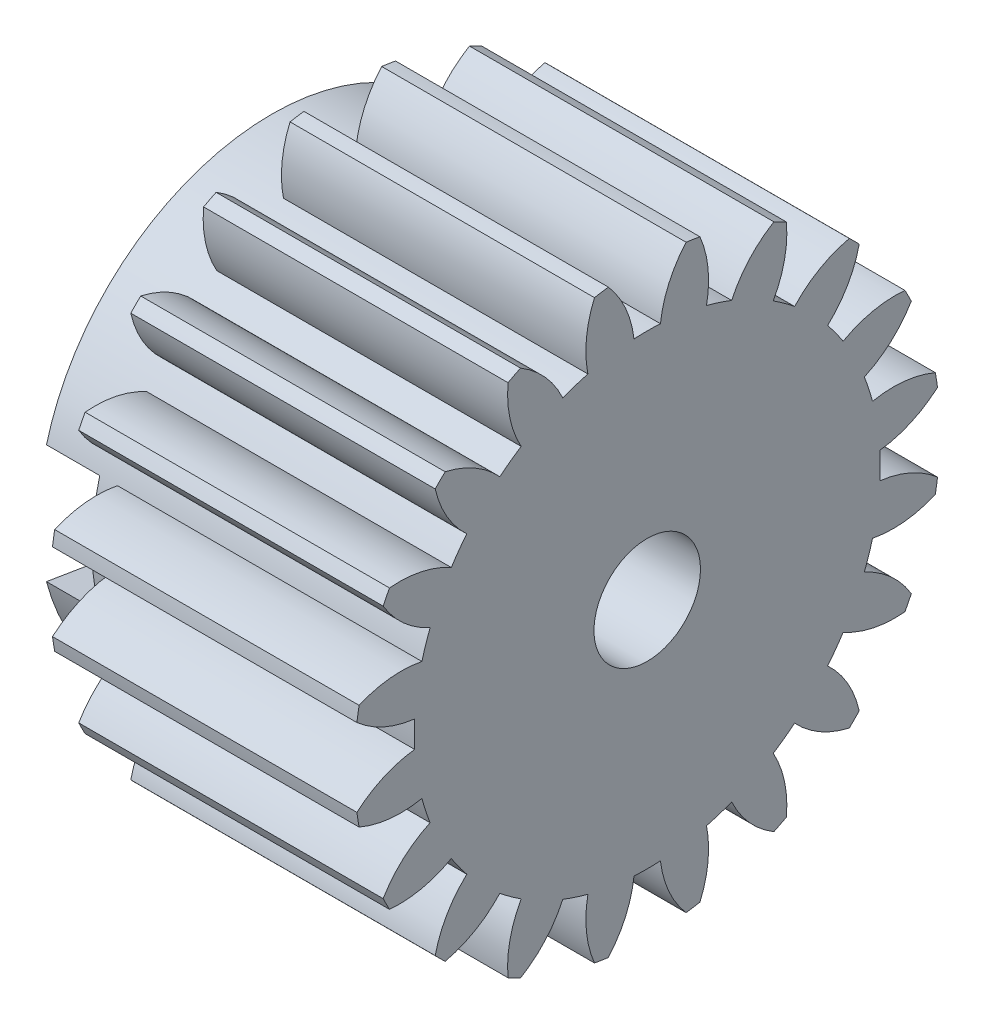
from build123d import *
from build123d.topology import SkipClean

# Parameters (mm, degrees)
BASPROSKE_W         = 10
BASPROSKE_H         = 16.5
TOOTHCUT_DEPTH      = 26.38700455
TEETHCUTS_COUNT     = 20
TEETHCUTS_ANGLE     = 342
HUBNEAONESKE_R      = 13.124
HUBNEARONE_DEPTH    = 6.0000508
BORSKE_R            = 0.4
BORE_DEPTH          = 16.0000508
CUT_EXTRUDE1_DEPTH  = 5
BOSS_EXTRUDE1_DEPTH = 7.15
SKETCH4_R           = 13.124
CUT_EXTRUDE2_DEPTH  = 2
SKETCH6_R           = 3
CUT_EXTRUDE3_DEPTH  = 13
SKETCH7_R           = 1.8
CUT_EXTRUDE4_DEPTH  = 27.531296609


with BuildPart() as part:
    # BasProSke → Base-Revolve (revolve)
    with BuildSketch(Plane(origin=(0, 0, 0), x_dir=(1, 0, 0), z_dir=(0, 1, 0)), mode=Mode.PRIVATE) as base_revolve_sk:
        with Locations((5, 8.25)):
            Rectangle(BASPROSKE_W, BASPROSKE_H)
    revolve(base_revolve_sk.sketch.rotate(Axis((-10, 0, 0), (1, 0, 0)), 180), axis=Axis((-10, 0, 0), (1, 0, 0)))

    # TooCutSke → ToothCut (cut, through all)
    with BuildSketch(Plane(origin=(0, 0, 0), x_dir=(0, 0, -1), z_dir=(1, 0, 0))):
        with BuildLine():
            ThreePointArc((0.74381438, 13.102904875), (0, 13.124), (-0.74381438, 13.102904875))
            ThreePointArc((-0.74381438, 13.102904875), (-1.226473103, 14.852072512), (-2.209965745, 16.376962373))
            ThreePointArc((-2.209965745, 16.376962373), (0, 16.5254), (2.209965745, 16.376962373))
            ThreePointArc((2.209965745, 16.376962373), (1.226473103, 14.852072512), (0.74381438, 13.102904875))
        make_face()
    toothcut = extrude(amount=TOOTHCUT_DEPTH, mode=Mode.SUBTRACT)

    # TeethCuts: ToothCut ×20 about axis
    teethcuts_axis = Axis((-10, 0, 0), (1, 0, 0))
    for i in range(1, TEETHCUTS_COUNT):
        add(toothcut.rotate(teethcuts_axis, i * TEETHCUTS_ANGLE / (TEETHCUTS_COUNT - 1)), mode=Mode.SUBTRACT)

    # HubNeaOneSke → HubNearOne (add)
    with SkipClean():  # the faces are left unmerged after this step: merging them gives an invalid solid
        with BuildSketch(Plane.ZY):
            Circle(HUBNEAONESKE_R)
        extrude(amount=HUBNEARONE_DEPTH)

    # BorSke → Bore (cut, symmetric)
    with SkipClean():  # the faces are left unmerged after this step: merging them gives an invalid solid
        with BuildSketch(Plane(origin=(0, 0, 0), x_dir=(0, 0, -1), z_dir=(1, 0, 0))):
            with Locations(Location((0, 0, 0), (0, 0, 180))):
                Circle(BORSKE_R)
        extrude(amount=BORE_DEPTH, both=True, mode=Mode.SUBTRACT)

    # Sketch1 → Cut-Extrude1 (cut)
    with SkipClean():  # the faces are left unmerged after this step: merging them gives an invalid solid
        with BuildSketch(Plane.ZY.offset(6.0000508)):
            with BuildLine():
                Line((15.95, 2.8), (4.417295553, 4.7))
                ThreePointArc((4.417295553, 4.7), (0, 6.45), (-4.417295553, 4.7))
                Line((-4.417295553, 4.7), (-15.95, 2.8))
                ThreePointArc((-15.95, 2.8), (-18.75, 0), (-15.95, -2.8))
                Line((-15.95, -2.8), (-4.417295553, -4.7))
                ThreePointArc((-4.417295553, -4.7), (0, -6.45), (4.417295553, -4.7))
                Line((4.417295553, -4.7), (15.95, -2.8))
                ThreePointArc((15.95, -2.8), (18.75, 0), (15.95, 2.8))
            make_face()
        extrude(amount=-CUT_EXTRUDE1_DEPTH, mode=Mode.SUBTRACT)

    # Sketch2 → Boss-Extrude1 (add)
    with SkipClean():  # the faces are left unmerged after this step: merging them gives an invalid solid
        with BuildSketch(Plane(origin=(10, 0, 0), x_dir=(0, 0, -1), z_dir=(1, 0, 0))):
            with BuildLine():
                ThreePointArc((-16.354046896, 2.189783121), (-14.838129876, 1.220250755), (-13.102904875, 0.74381438))
                ThreePointArc((-13.102904875, 0.74381438), (-13.124, 0), (-13.102904875, -0.74381438))
                ThreePointArc((-13.102904875, -0.74381438), (-14.838129876, -1.220250755), (-16.354046896, -2.189783121))
                ThreePointArc((-16.354046896, -2.189783121), (-16.29685762, -2.581168673), (-16.230303067, -2.971070911))
                ThreePointArc((-16.230303067, -2.971070911), (-14.488978329, -3.424706864), (-12.691454348, -3.341610769))
                ThreePointArc((-12.691454348, -3.341610769), (-12.48166572, -4.055539034), (-12.23175178, -4.756429795))
                ThreePointArc((-12.23175178, -4.756429795), (-13.734821887, -5.745761728), (-14.87694267, -7.136285925))
                ThreePointArc((-14.87694267, -7.136285925), (-14.701607649, -7.490843246), (-14.51782409, -7.841095822))
                ThreePointArc((-14.51782409, -7.841095822), (-12.721544632, -7.734430314), (-11.037675843, -7.099935773))
                ThreePointArc((-11.037675843, -7.099935773), (-10.617539034, -7.714093651), (-10.163269596, -8.303452722))
                ThreePointArc((-10.163269596, -8.303452722), (-11.287053836, -9.708837511), (-11.943579641, -11.38423934))
                ThreePointArc((-11.943579641, -11.38423934), (-11.66726189, -11.66726189), (-11.38423934, -11.943579641))
                ThreePointArc((-11.38423934, -11.943579641), (-9.708837511, -11.287053836), (-8.303452722, -10.163269596))
                ThreePointArc((-8.303452722, -10.163269596), (-7.714093651, -10.617539034), (-7.099935773, -11.037675843))
                ThreePointArc((-7.099935773, -11.037675843), (-7.734430314, -12.721544632), (-7.841095822, -14.51782409))
                ThreePointArc((-7.841095822, -14.51782409), (-7.490843246, -14.701607649), (-7.136285925, -14.87694267))
                ThreePointArc((-7.136285925, -14.87694267), (-5.745761728, -13.734821887), (-4.756429795, -12.23175178))
                ThreePointArc((-4.756429795, -12.23175178), (-4.055539034, -12.48166572), (-3.341610769, -12.691454348))
                ThreePointArc((-3.341610769, -12.691454348), (-3.424706864, -14.488978329), (-2.971070911, -16.230303067))
                ThreePointArc((-2.971070911, -16.230303067), (-2.581168673, -16.29685762), (-2.189783121, -16.354046896))
                ThreePointArc((-2.189783121, -16.354046896), (-1.220250755, -14.838129876), (-0.74381438, -13.102904875))
                ThreePointArc((-0.74381438, -13.102904875), (0, -13.124), (0.74381438, -13.102904875))
                ThreePointArc((0.74381438, -13.102904875), (1.220250755, -14.838129876), (2.189783121, -16.354046896))
                ThreePointArc((2.189783121, -16.354046896), (2.581168673, -16.29685762), (2.971070911, -16.230303067))
                ThreePointArc((2.971070911, -16.230303067), (3.424706864, -14.488978329), (3.341610769, -12.691454348))
                ThreePointArc((3.341610769, -12.691454348), (4.055539034, -12.48166572), (4.756429795, -12.23175178))
                ThreePointArc((4.756429795, -12.23175178), (5.745761728, -13.734821887), (7.136285925, -14.87694267))
                ThreePointArc((7.136285925, -14.87694267), (7.490843246, -14.701607649), (7.841095822, -14.51782409))
                ThreePointArc((7.841095822, -14.51782409), (7.734430314, -12.721544632), (7.099935773, -11.037675843))
                ThreePointArc((7.099935773, -11.037675843), (7.714093651, -10.617539034), (8.303452722, -10.163269596))
                ThreePointArc((8.303452722, -10.163269596), (9.708837511, -11.287053836), (11.38423934, -11.943579641))
                ThreePointArc((11.38423934, -11.943579641), (11.66726189, -11.66726189), (11.943579641, -11.38423934))
                ThreePointArc((11.943579641, -11.38423934), (11.287053836, -9.708837511), (10.163269596, -8.303452722))
                ThreePointArc((10.163269596, -8.303452722), (10.617539034, -7.714093651), (11.037675843, -7.099935773))
                ThreePointArc((11.037675843, -7.099935773), (12.721544632, -7.734430314), (14.51782409, -7.841095822))
                ThreePointArc((14.51782409, -7.841095822), (14.701607649, -7.490843246), (14.87694267, -7.136285925))
                ThreePointArc((14.87694267, -7.136285925), (13.734821887, -5.745761728), (12.23175178, -4.756429795))
                ThreePointArc((12.23175178, -4.756429795), (12.48166572, -4.055539034), (12.691454348, -3.341610769))
                ThreePointArc((12.691454348, -3.341610769), (14.488978329, -3.424706864), (16.230303067, -2.971070911))
                ThreePointArc((16.230303067, -2.971070911), (16.29685762, -2.581168673), (16.354046896, -2.189783121))
                ThreePointArc((16.354046896, -2.189783121), (14.838129876, -1.220250755), (13.102904875, -0.74381438))
                ThreePointArc((13.102904875, -0.74381438), (13.124, 0), (13.102904875, 0.74381438))
                ThreePointArc((13.102904875, 0.74381438), (14.838129876, 1.220250755), (16.354046896, 2.189783121))
                ThreePointArc((16.354046896, 2.189783121), (16.29685762, 2.581168673), (16.230303067, 2.971070911))
                ThreePointArc((16.230303067, 2.971070911), (14.488978329, 3.424706864), (12.691454348, 3.341610769))
                ThreePointArc((12.691454348, 3.341610769), (12.48166572, 4.055539034), (12.23175178, 4.756429795))
                ThreePointArc((12.23175178, 4.756429795), (13.734821887, 5.745761728), (14.87694267, 7.136285925))
                ThreePointArc((14.87694267, 7.136285925), (14.701607649, 7.490843246), (14.51782409, 7.841095822))
                ThreePointArc((14.51782409, 7.841095822), (12.721544632, 7.734430314), (11.037675843, 7.099935773))
                ThreePointArc((11.037675843, 7.099935773), (10.617539034, 7.714093651), (10.163269596, 8.303452722))
                ThreePointArc((10.163269596, 8.303452722), (11.287053836, 9.708837511), (11.943579641, 11.38423934))
                ThreePointArc((11.943579641, 11.38423934), (11.66726189, 11.66726189), (11.38423934, 11.943579641))
                ThreePointArc((11.38423934, 11.943579641), (9.708837511, 11.287053836), (8.303452722, 10.163269596))
                ThreePointArc((8.303452722, 10.163269596), (7.714093651, 10.617539034), (7.099935773, 11.037675843))
                ThreePointArc((7.099935773, 11.037675843), (7.734430314, 12.721544632), (7.841095822, 14.51782409))
                ThreePointArc((7.841095822, 14.51782409), (7.490843246, 14.701607649), (7.136285925, 14.87694267))
                ThreePointArc((7.136285925, 14.87694267), (5.745761728, 13.734821887), (4.756429795, 12.23175178))
                ThreePointArc((4.756429795, 12.23175178), (4.055539034, 12.48166572), (3.341610769, 12.691454348))
                ThreePointArc((3.341610769, 12.691454348), (3.424706864, 14.488978329), (2.971070911, 16.230303067))
                ThreePointArc((2.971070911, 16.230303067), (2.581168673, 16.29685762), (2.189783121, 16.354046896))
                ThreePointArc((2.189783121, 16.354046896), (1.220250755, 14.838129876), (0.74381438, 13.102904875))
                ThreePointArc((0.74381438, 13.102904875), (0, 13.124), (-0.74381438, 13.102904875))
                ThreePointArc((-0.74381438, 13.102904875), (-1.220250755, 14.838129876), (-2.189783121, 16.354046896))
                ThreePointArc((-2.189783121, 16.354046896), (-2.581168673, 16.29685762), (-2.971070911, 16.230303067))
                ThreePointArc((-2.971070911, 16.230303067), (-3.424706864, 14.488978329), (-3.341610769, 12.691454348))
                ThreePointArc((-3.341610769, 12.691454348), (-4.055539034, 12.48166572), (-4.756429795, 12.23175178))
                ThreePointArc((-4.756429795, 12.23175178), (-5.745761728, 13.734821887), (-7.136285925, 14.87694267))
                ThreePointArc((-7.136285925, 14.87694267), (-7.490843246, 14.701607649), (-7.841095822, 14.51782409))
                ThreePointArc((-7.841095822, 14.51782409), (-7.734430314, 12.721544632), (-7.099935773, 11.037675843))
                ThreePointArc((-7.099935773, 11.037675843), (-7.714093651, 10.617539034), (-8.303452722, 10.163269596))
                ThreePointArc((-8.303452722, 10.163269596), (-9.708837511, 11.287053836), (-11.38423934, 11.943579641))
                ThreePointArc((-11.38423934, 11.943579641), (-11.66726189, 11.66726189), (-11.943579641, 11.38423934))
                ThreePointArc((-11.943579641, 11.38423934), (-11.287053836, 9.708837511), (-10.163269596, 8.303452722))
                ThreePointArc((-10.163269596, 8.303452722), (-10.617539034, 7.714093651), (-11.037675843, 7.099935773))
                ThreePointArc((-11.037675843, 7.099935773), (-12.721544632, 7.734430314), (-14.51782409, 7.841095822))
                ThreePointArc((-14.51782409, 7.841095822), (-14.701607649, 7.490843246), (-14.87694267, 7.136285925))
                ThreePointArc((-14.87694267, 7.136285925), (-13.734821887, 5.745761728), (-12.23175178, 4.756429795))
                ThreePointArc((-12.23175178, 4.756429795), (-12.48166572, 4.055539034), (-12.691454348, 3.341610769))
                ThreePointArc((-12.691454348, 3.341610769), (-14.488978329, 3.424706864), (-16.230303067, 2.971070911))
                ThreePointArc((-16.230303067, 2.971070911), (-16.29685762, 2.581168673), (-16.354046896, 2.189783121))
            make_face()
        extrude(amount=BOSS_EXTRUDE1_DEPTH)

    # Sketch4 → Cut-Extrude2 (cut)
    with SkipClean():  # the faces are left unmerged after this step: merging them gives an invalid solid
        with BuildSketch(Plane.ZY.offset(6.0000508)):
            with Locations(Location((0, 0, 0), (0, 0, 3.249030282))):
                Circle(SKETCH4_R)
        extrude(amount=-CUT_EXTRUDE2_DEPTH, mode=Mode.SUBTRACT)

    # Sketch6 → Cut-Extrude3 (cut)
    with SkipClean():  # the faces are left unmerged after this step: merging them gives an invalid solid
        with BuildSketch(Plane(origin=(17.15, 0, 0), x_dir=(0, 0, -1), z_dir=(1, 0, 0))):
            Circle(SKETCH6_R)
        extrude(amount=-CUT_EXTRUDE3_DEPTH, mode=Mode.SUBTRACT)

    # Sketch7 → Cut-Extrude4 (cut, through all)
    with SkipClean():  # the faces are left unmerged after this step: merging them gives an invalid solid
        with BuildSketch(Plane(origin=(4.15, 0, 0), x_dir=(0, 0, -1), z_dir=(1, 0, 0))):
            Circle(SKETCH7_R)
        extrude(amount=-CUT_EXTRUDE4_DEPTH, mode=Mode.SUBTRACT)


solid = part.part
